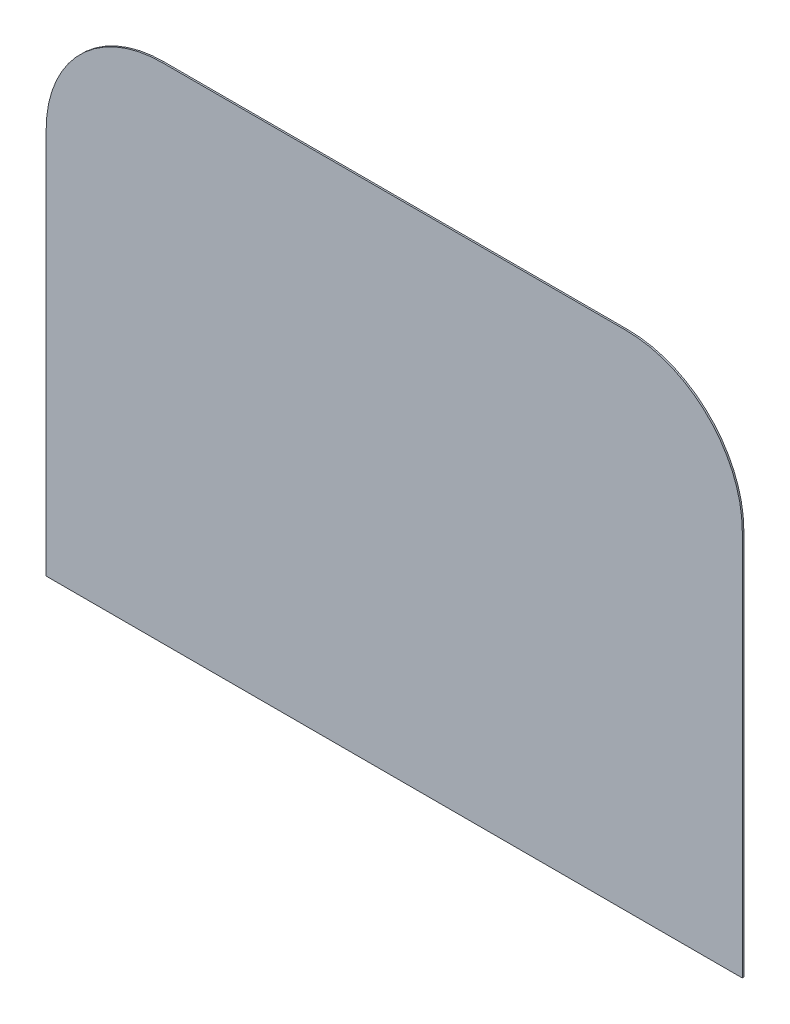
from build123d import *

# Parameters (mm, degrees)
EXTRUDE_2_DEPTH = 1


with BuildPart() as part:
    # Эскиз1 → Бобышка-Вытянуть2 (new body)
    with BuildSketch(Plane.XY):
        with BuildLine():
            Line((-152.649098001, -86.991869919), (-152.649098001, 163.008130081))
            ThreePointArc((-152.649098001, 163.008130081), (-130.68210659, 216.04113867), (-77.649098001, 238.008130081))
            Line((-77.649098001, 238.008130081), (222.350901999, 238.008130081))
            ThreePointArc((222.350901999, 238.008130081), (275.383910588, 216.04113867), (297.350901999, 163.008130081))
            Line((297.350901999, 163.008130081), (297.350901999, -86.991869919))
            Line((297.350901999, -86.991869919), (272.350901999, -86.991869919))
            Line((272.350901999, -86.991869919), (-152.649098001, -86.991869919))
        make_face()
    extrude(amount=EXTRUDE_2_DEPTH)


solid = part.part
